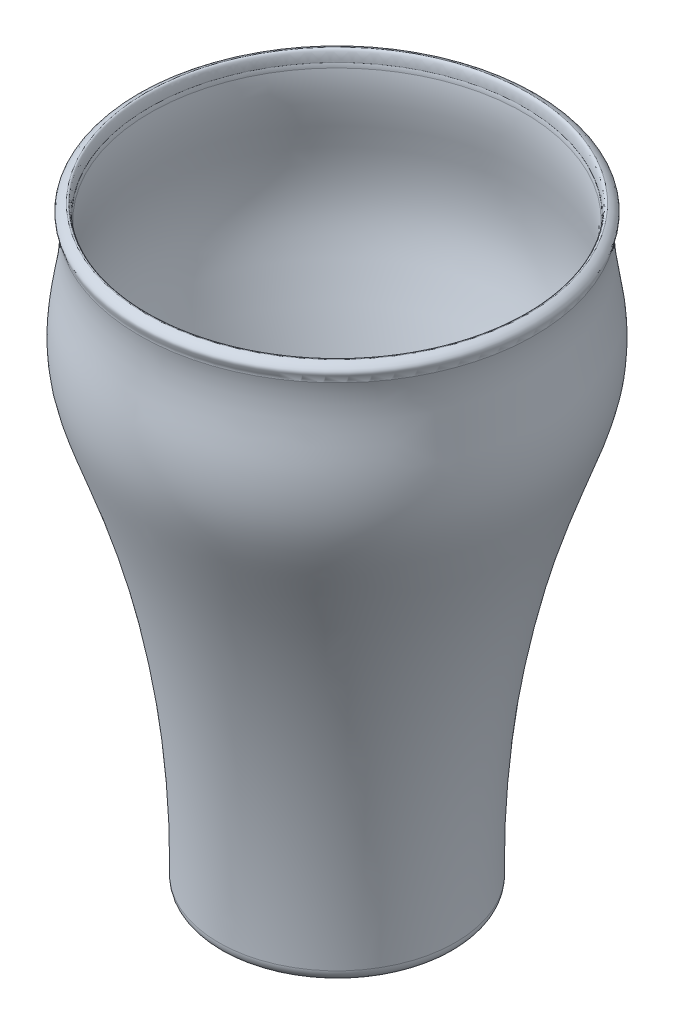
from build123d import *

# Parameters (mm, degrees)
FILLET1_R = 2.54
FILLET2_R = 2.54


with BuildPart() as part:
    # Sketch2 → Revolve1 (revolve)
    with BuildSketch(Plane.XY):
        with BuildLine():
            Line((-25.40708286, -56.962721203), (0, -56.962721203))
            Line((0, -56.962721203), (0, -54.689421203))
            Line((0, -54.689421203), (-2.2733, -54.689421203))
            Line((-2.2733, -54.689421203), (-23.096843174, -54.689421203))
            add(Edge.make_bspline(
                [(-40.011466118, 66.827486807), (-39.892609453, 66.115369341), (-39.734285644, 64.664702424), (-39.695586841, 61.847294194), (-40.165710855, 57.055854379), (-41.187764333, 52.048129172), (-41.649914027, 47.172076733), (-41.672692613, 43.49645079), (-41.324964806, 39.917518025), (-40.302545165, 35.210106246), (-38.21994674, 29.231854528), (-35.55783051, 21.930169756), (-33.063765776, 14.572130603), (-30.118090667, 4.593275441), (-27.138534071, -8.08213544), (-24.664040822, -23.53049359), (-23.267146809, -39.111739175), (-23.038801881, -49.49560103), (-23.096843174, -54.689421203)],
                knots=[0.001517313, 0.001517313, 0.001517313, 0.001517313, 0.016832761, 0.032148209, 0.062779106, 0.124040899, 0.154671795, 0.185302691, 0.215933588, 0.246564484, 0.307826277, 0.36908807, 0.430349863, 0.491611656, 0.614135242, 0.736658828, 0.859182413, 0.981705999, 0.981705999, 0.981705999, 0.981705999], degree=3))
            add(Edge.make_bspline(
                [(-40.161712897, 67.763978797), (-40.143235386, 67.698536297), (-40.110184851, 67.572053011), (-40.063524101, 67.348796279), (-40.027766705, 67.105802402), (-40.014203281, 66.918310744), (-40.011466118, 66.827486807)],
                knots=[0.882607163, 0.882607163, 0.882607163, 0.882607163, 0.905087451, 0.927567739, 0.950048027, 0.972528315, 0.972528315, 0.972528315, 0.972528315], degree=3))
            add(Edge.make_bspline(
                [(-40.161712897, 67.763978797), (-40.207860765, 67.571707559), (-40.107131029, 70.315751952), (-40.982771359, 70.037278797)],
                knots=[0, 0, 0, 0, 1, 1, 1, 1], degree=3))
            add(Edge.make_bspline(
                [(-40.982771359, 70.037278797), (-41.254090727, 69.950993186), (-42.056088349, 69.597301664), (-43.200594852, 68.443015921), (-42.23328971, 67.309077752), (-42.286452081, 66.642614038)],
                knots=[0, 0, 0, 0, 0.262566933, 0.525656659, 1, 1, 1, 1], degree=3))
            add(Edge.make_bspline(
                [(-42.286452081, 66.642614038), (-41.785134146, 63.834319752), (-42.206541361, 58.426928392), (-43.97552502, 49.627897193), (-44.138098089, 39.061746927), (-40.010316103, 27.521804127), (-28.807269236, -3.417799297), (-24.892324559, -32.552242663), (-25.40708286, -56.962721203)],
                knots=[0, 0, 0, 0, 0.067526005, 0.127886177, 0.21432733, 0.314756995, 0.41692523, 1, 1, 1, 1], degree=3))
        make_face()
    revolve(axis=Axis((0, 70.037278797, 0), (0, -1, 0)))

    # Fillet1
    fillet1_edges = [part.edges().sort_by_distance(p)[0] for p in [
        (23.096843174, -54.689421203, 0),
    ]]
    fillet(fillet1_edges, radius=FILLET1_R)

    # Fillet2
    fillet2_edges = [part.edges().sort_by_distance(p)[0] for p in [
        (25.40708286, -56.962721203, 0),
    ]]
    fillet(fillet2_edges, radius=FILLET2_R)


solid = part.part
